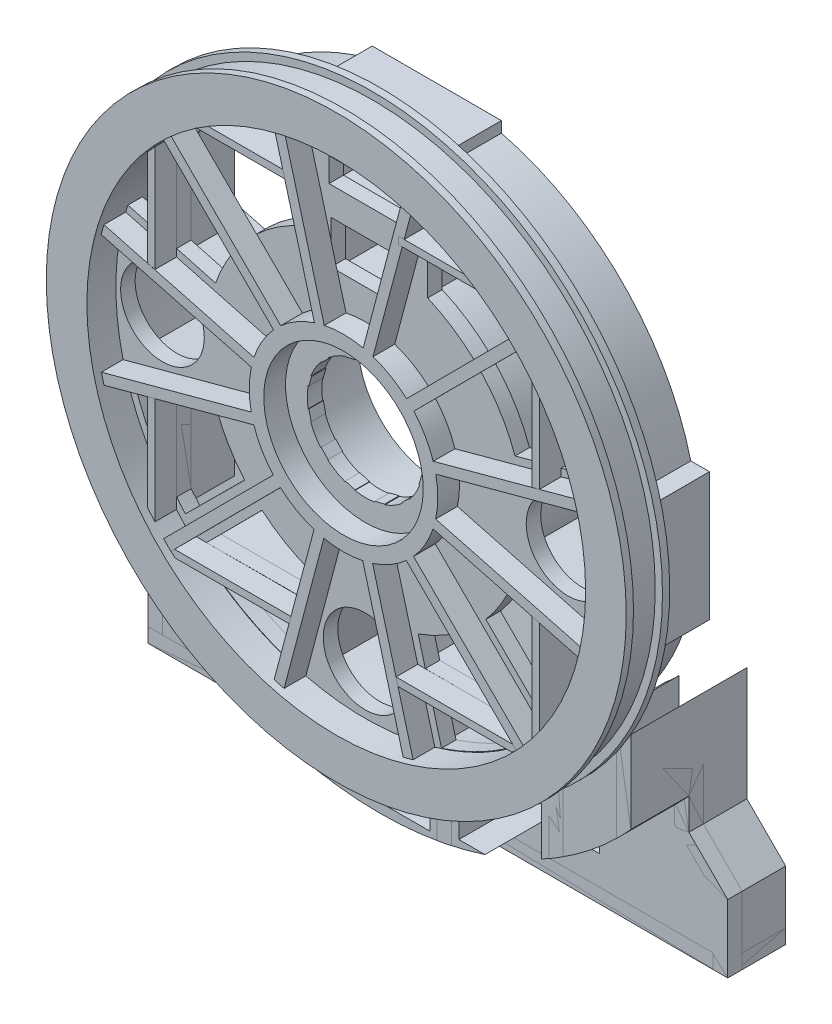
from build123d import *
from build123d.topology import SkipClean

# Parameters (mm, degrees)
SKETCH1_R                   = 200
BOSS_EXTRUDE1_DEPTH         = 5
SKETCH2_R                   = 195
BOSS_EXTRUDE2_DEPTH         = 10
SKETCH4_R                   = 180
SKETCH4_R_2                 = 172
BOSS_EXTRUDE3_DEPTH         = 40
CUT_EXTRUDE1_DEPTH          = 286.657137142
CUT_EXTRUDE1_DEPTH_BACK     = 286.657137142
SKETCH6_R                   = 40
SKETCH7_R                   = 172
CUT_EXTRUDE2_DEPTH          = 20
BOSS_EXTRUDE12_START        = -25
BOSS_EXTRUDE12_DEPTH        = 65
CIRPATTERN7_COUNT           = 12
SKETCH5_R                   = 104.5
SKETCH5_R_2                 = 96.5
BOSS_EXTRUDE14_DEPTH        = 40
SKETCH16_R                  = 63
SKETCH16_R_2                = 55
BOSS_EXTRUDE15_DEPTH        = 40
CUT_EXTRUDE9_START          = -40
SKETCH18_R                  = 55
CUT_EXTRUDE9_DEPTH          = 40
CUT_EXTRUDE13_DEPTH         = 40
BOSS_EXTRUDE18_START        = -40
SKETCH25_W                  = 60.032294261
SKETCH25_H                  = 45.012979572
BOSS_EXTRUDE18_DEPTH        = 40
SKETCH27_W                  = 60.032294261
SKETCH27_H                  = 45.012979572
SKETCH27_H_2                = 26.987020428
CUT_EXTRUDE15_DEPTH         = 40
CUT_EXTRUDE16_START         = -35
CUT_EXTRUDE16_DEPTH         = 35
BOSS_EXTRUDE19_START        = -44
SKETCH31_W                  = 5.866847787
SKETCH31_H                  = 9.437366397
SKETCH31_W_2                = 76.032294261
SKETCH31_W_3                = 7.195155409
BOSS_EXTRUDE19_DEPTH        = 44
BOSS_EXTRUDE20_DEPTH        = 80
BOSS_EXTRUDE21_DEPTH        = 80
BOSS_EXTRUDE21_2_DEPTH      = 80
BOSS_EXTRUDE26_DEPTH        = 50
CUT_EXTRUDE17_DEPTH         = 40
SKETCH41_W                  = 400
SKETCH41_H                  = 137.842811608
CUT_EXTRUDE18_DEPTH         = 452.7492864
BOSS_EXTRUDE29_DEPTH        = 40
BOSS_EXTRUDE29_DEPTH_BACK   = 10
SKETCH42_W                  = 400
SKETCH42_H                  = 10
BOSS_EXTRUDE31_DEPTH        = 40
CUT_EXTRUDE19_DEPTH         = 332.517722
CUT_EXTRUDE20_DEPTH         = 10
BOSS_EXTRUDE35_DEPTH        = 30
BOSS_EXTRUDE35_DEPTH_BACK   = 25
BOSS_EXTRUDE35_2_DEPTH      = 30
BOSS_EXTRUDE35_2_DEPTH_BACK = 25
BOSS_EXTRUDE35_3_DEPTH      = 30
BOSS_EXTRUDE35_3_DEPTH_BACK = 25
BOSS_EXTRUDE35_4_DEPTH      = 30
BOSS_EXTRUDE35_4_DEPTH_BACK = 25
BOSS_EXTRUDE35_5_DEPTH      = 30
BOSS_EXTRUDE35_5_DEPTH_BACK = 25
BOSS_EXTRUDE35_6_DEPTH      = 30
BOSS_EXTRUDE35_6_DEPTH_BACK = 25
BOSS_EXTRUDE35_7_DEPTH      = 30
BOSS_EXTRUDE35_7_DEPTH_BACK = 25
BOSS_EXTRUDE35_8_DEPTH      = 30
BOSS_EXTRUDE35_8_DEPTH_BACK = 25
CUT_EXTRUDE22_START         = -10.1
SKETCH51_W                  = 47.279154804
SKETCH51_H                  = 29.689444604
SKETCH51_W_2                = 50.032294261
SKETCH51_H_2                = 16.730666638
SKETCH51_H_3                = 10.868299713
SKETCH51_R                  = 28.871670661
SKETCH51_R_2                = 28.980669561
CUT_EXTRUDE22_DEPTH         = 10.1
BOSS_EXTRUDE36_START        = 15
SKETCH54_R                  = 65
SKETCH54_R_2                = 55
BOSS_EXTRUDE36_DEPTH        = 15
SKETCH55_R                  = 55
CUT_EXTRUDE23_DEPTH         = 15


with BuildPart() as part:
    # Sketch1 → Boss-Extrude1 (new body)
    with BuildSketch(Plane.XY):
        Circle(SKETCH1_R)
    boss_extrude1 = extrude(amount=BOSS_EXTRUDE1_DEPTH)

    # Sketch2 → Boss-Extrude2 (add)
    with BuildSketch(Plane.XY.offset(5)):
        Circle(SKETCH2_R)
    boss_extrude2 = extrude(amount=BOSS_EXTRUDE2_DEPTH)

    # Mirror2: Boss-Extrude2 across plane
    add(boss_extrude2.mirror(Plane.XY.offset(15)))

    # Mirror3: Boss-Extrude1 across plane
    add(boss_extrude1.mirror(Plane.XY.offset(15)))

    # Sketch4 → Boss-Extrude3 (add)
    with BuildSketch(Plane.XY):
        Circle(SKETCH4_R)
        Circle(SKETCH4_R_2, mode=Mode.SUBTRACT)
    extrude(amount=-BOSS_EXTRUDE3_DEPTH)

    # Sketch6 → Cut-Extrude1 (cut, two sides: drawn at the far end of the back side and taken through both)
    with BuildSketch(Plane(origin=(0, 0, 0), x_dir=(-1, 0, 0), z_dir=(0, 0, -1)).offset(-CUT_EXTRUDE1_DEPTH_BACK)):
        Circle(SKETCH6_R)
    extrude(amount=CUT_EXTRUDE1_DEPTH + CUT_EXTRUDE1_DEPTH_BACK, mode=Mode.SUBTRACT)

    # Sketch7 → Cut-Extrude2 (cut)
    with BuildSketch(Plane.XY.offset(30)):
        Circle(SKETCH7_R)
    extrude(amount=-CUT_EXTRUDE2_DEPTH, mode=Mode.SUBTRACT)

    # Sketch11 → Boss-Extrude12 (add)
    with BuildSketch(Plane(origin=(0, 0, 0), x_dir=(-1, 0, 0), z_dir=(0, 0, -1)).offset(BOSS_EXTRUDE12_START)):
        Polygon((7.035778174, -38.94988518), (13.739038842, -37.032866306), (48.739799741, -168.484156352), (41.858359492, -170.324504337), align=None)
    boss_extrude12 = extrude(amount=BOSS_EXTRUDE12_DEPTH)

    # CirPattern7: Boss-Extrude12 ×12 about axis
    cirpattern7_axis = Axis((0, 0, 0), (0, 0, 1))
    for i in range(1, CIRPATTERN7_COUNT):
        add(boss_extrude12.rotate(cirpattern7_axis, i * 360 / CIRPATTERN7_COUNT))

    # Sketch5 → Boss-Extrude14 (add)
    with BuildSketch(Plane(origin=(0, 0, 0), x_dir=(-1, 0, 0), z_dir=(0, 0, -1))):
        Circle(SKETCH5_R)
        Circle(SKETCH5_R_2, mode=Mode.SUBTRACT)
    extrude(amount=BOSS_EXTRUDE14_DEPTH)

    # Sketch16 → Boss-Extrude15 (add)
    with BuildSketch(Plane(origin=(0, 0, 0), x_dir=(-1, 0, 0), z_dir=(0, 0, -1))):
        Circle(SKETCH16_R)
        Circle(SKETCH16_R_2, mode=Mode.SUBTRACT)
    extrude(amount=BOSS_EXTRUDE15_DEPTH)

    # Sketch18 → Cut-Extrude9 (cut)
    with BuildSketch(Plane(origin=(0, 0, -40), x_dir=(-1, 0, 0), z_dir=(0, 0, -1)).offset(CUT_EXTRUDE9_START)):
        Circle(SKETCH18_R)
    extrude(amount=CUT_EXTRUDE9_DEPTH, mode=Mode.SUBTRACT)

    # Sketch20 → Cut-Extrude13 (cut)
    with SkipClean():  # the faces are left unmerged after this step: merging them gives an invalid solid
        with BuildSketch(Plane(origin=(0, 0, 0), x_dir=(-1, 0, 0), z_dir=(0, 0, -1))):
            with BuildLine():
                Line((-76.383232436, 71.315158295), (-124.056442132, 119.138571275))
                ThreePointArc((-124.056442132, 119.138571275), (0.082293709, 171.999980313), (124.170389449, 119.019806688))
                Line((124.170389449, 119.019806688), (76.298786502, 71.405498236))
                ThreePointArc((76.298786502, 71.405498236), (-0.061831263, 104.499981708), (-76.383232436, 71.315158295))
            make_face()
            with BuildLine():
                Line((-70.731344821, 65.645463361), (-47.053181493, 41.892697591))
                ThreePointArc((-47.053181493, 41.892697591), (-0.150655715, 62.999819864), (46.85228282, 42.117260055))
                Line((46.85228282, 42.117260055), (70.623866336, 65.761078943))
                ThreePointArc((70.623866336, 65.761078943), (-0.078928112, 96.499967722), (-70.731344821, 65.645463361))
            make_face()
        extrude(amount=CUT_EXTRUDE13_DEPTH, mode=Mode.SUBTRACT)

    # Sketch25 → Boss-Extrude18 (add)
    with SkipClean():  # the faces are left unmerged after this step: merging them gives an invalid solid
        with BuildSketch(Plane(origin=(0, 0, -40), x_dir=(-1, 0, 0), z_dir=(0, 0, -1)).offset(BOSS_EXTRUDE18_START)):
            with BuildLine():
                Line((38, 39.761790704), (38, 175.943172644))
                ThreePointArc((38, 175.943172644), (34.008709182, 176.758048472), (30, 177.482393493))
                Line((30, 177.482393493), (30, 130))
                Line((30, 130), (-30.032294261, 130))
                Line((-30.032294261, 130), (-30.032294261, 177.476931744))
                ThreePointArc((-30.032294261, 177.476931744), (-34.041012328, 176.751830202), (-38.032294261, 175.936194665))
                Line((-38.032294261, 175.936194665), (-38.032294261, 39.730902246))
                ThreePointArc((-38.032294261, 39.730902246), (-34.179881599, 43.089856044), (-30.032294261, 46.07668935))
                Line((-30.032294261, 46.07668935), (-30.032294261, 66.987020428))
                Line((-30.032294261, 66.987020428), (30, 66.987020428))
                Line((30, 66.987020428), (30, 46.097722286))
                ThreePointArc((30, 46.097722286), (34.147269397, 43.115704711), (38, 39.761790704))
            make_face()
            with Locations((-0.01614713, 99.493510214)):
                Rectangle(SKETCH25_W, SKETCH25_H, mode=Mode.SUBTRACT)
        extrude(amount=BOSS_EXTRUDE18_DEPTH)

    # Sketch27 → Cut-Extrude15 (cut)
    with SkipClean():  # the faces are left unmerged after this step: merging them gives an invalid solid
        with BuildSketch(Plane(origin=(0, 0, 0), x_dir=(-1, 0, 0), z_dir=(0, 0, -1))):
            with Locations((-0.01614713, 99.493510214)):
                Rectangle(SKETCH27_W, SKETCH27_H)
            with Locations((-0.01614713, 53.493510214)):
                Rectangle(SKETCH27_W, SKETCH27_H_2)
        extrude(amount=CUT_EXTRUDE15_DEPTH, mode=Mode.SUBTRACT)

    # Sketch30 → Cut-Extrude16 (cut)
    with SkipClean():  # the faces are left unmerged after this step: merging them gives an invalid solid
        with BuildSketch(Plane(origin=(0, 0, -50), x_dir=(-1, 0, 0), z_dir=(0, 0, -1)).offset(CUT_EXTRUDE16_START)):
            with BuildLine():
                Line((-38.032294261, 130), (38, 130))
                Line((38, 130), (38, 167.749813711))
                ThreePointArc((38, 167.749813711), (-0.016556603, 171.999999203), (-38.032294261, 167.742494894))
                Line((-38.032294261, 167.742494894), (-38.032294261, 130))
            make_face()
        extrude(amount=CUT_EXTRUDE16_DEPTH, mode=Mode.SUBTRACT)

    # Sketch31 → Boss-Extrude19 (add)
    with SkipClean():  # the faces are left unmerged after this step: merging them gives an invalid solid
        with BuildSketch(Plane(origin=(0, 0, -40), x_dir=(-1, 0, 0), z_dir=(0, 0, -1)).offset(BOSS_EXTRUDE19_START)):
            with BuildLine():
                ThreePointArc((-43.899142048, 166.303533719), (-40.972035783, 167.048772171), (-38.032294261, 167.742494894))
                Line((-38.032294261, 167.742494894), (-38.032294261, 172.64311533))
                Line((-38.032294261, 172.64311533), (-43.899142048, 172.64311533))
                Line((-43.899142048, 172.64311533), (-43.899142048, 166.303533719))
            make_face()
            with Locations((-40.965718155, 177.361798529)):
                Rectangle(SKETCH31_W, SKETCH31_H)
            with Locations((-0.016147131, 177.361798529)):
                Rectangle(SKETCH31_W_2, SKETCH31_H)
            with BuildLine():
                Line((-38.032294261, 172.64311533), (-38.032294261, 167.742494894))
                ThreePointArc((-38.032294261, 167.742494894), (-0.016556603, 171.999999203), (38, 167.749813711))
                Line((38, 167.749813711), (38, 172.64311533))
                Line((38, 172.64311533), (-38.032294261, 172.64311533))
            make_face()
            with BuildLine():
                Line((38, 172.64311533), (38, 167.749813711))
                ThreePointArc((38, 167.749813711), (41.607245787, 166.891692717), (45.195155409, 165.956012026))
                Line((45.195155409, 165.956012026), (45.195155409, 172.64311533))
                Line((45.195155409, 172.64311533), (38, 172.64311533))
            make_face()
            with Locations((41.597577704, 177.361798529)):
                Rectangle(SKETCH31_W_3, SKETCH31_H)
        extrude(amount=BOSS_EXTRUDE19_DEPTH)

    # Sketch32 → Boss-Extrude20 (add)
    with SkipClean():  # the faces are left unmerged after this step: merging them gives an invalid solid
        with BuildSketch(Plane.XY):
            with BuildLine():
                Line((125.869176934, -389.842811608), (126.470649272, -154.528527603))
                ThreePointArc((126.470649272, -154.528527603), (121.628078628, -158.368246375), (116.66900432, -162.056269245))
                Line((116.66900432, -162.056269245), (116.086773179, -389.842811608))
                Line((116.086773179, -389.842811608), (125.869176934, -389.842811608))
            make_face()
            with BuildLine():
                Line((126.470649272, -154.528527603), (126.538416981, -128.015737423))
                ThreePointArc((126.538416981, -128.015737423), (121.718930634, -132.606568183), (116.733008017, -137.016075113))
                Line((116.733008017, -137.016075113), (116.66900432, -162.056269245))
                ThreePointArc((116.66900432, -162.056269245), (121.628078628, -158.368246375), (126.470649272, -154.528527603))
            make_face()
            with BuildLine():
                Line((49.586808273, -193.429675634), (49.586808273, -173.035107551))
                ThreePointArc((49.586808273, -173.035107551), (44.605146714, -174.385724435), (39.586808273, -175.592951484))
                Line((39.586808273, -175.592951484), (39.586808273, -195.721167944))
                ThreePointArc((39.586808273, -195.721167944), (44.601526949, -194.639653628), (49.586808273, -193.429675634))
            make_face()
            with BuildLine():
                Line((49.586808273, -389.842811608), (49.586808273, -193.429675634))
                ThreePointArc((49.586808273, -193.429675634), (44.601526949, -194.639653628), (39.586808273, -195.721167944))
                Line((39.586808273, -195.721167944), (39.586808273, -389.842811608))
                Line((39.586808273, -389.842811608), (49.586808273, -389.842811608))
            make_face()
            with BuildLine():
                ThreePointArc((-39.427863087, -175.628709534), (-44.446127643, -174.426321802), (-49.427863087, -173.080577624))
                Line((-49.427863087, -173.080577624), (-49.427863087, -193.470352564))
                ThreePointArc((-49.427863087, -193.470352564), (-44.442523811, -194.676020731), (-39.427863087, -195.753249227))
                Line((-39.427863087, -195.753249227), (-39.427863087, -175.628709534))
            make_face()
            with BuildLine():
                ThreePointArc((-39.427863087, -195.753249227), (-44.442523811, -194.676020731), (-49.427863087, -193.470352564))
                Line((-49.427863087, -193.470352564), (-49.427863087, -389.842811608))
                Line((-49.427863087, -389.842811608), (-39.427863087, -389.842811608))
                Line((-39.427863087, -389.842811608), (-39.427863087, -195.753249227))
            make_face()
            with BuildLine():
                ThreePointArc((-116.53812441, -137.181870373), (-121.624499416, -132.693184233), (-126.53812441, -128.016026617))
                Line((-126.53812441, -128.016026617), (-126.53812441, -154.473279376))
                ThreePointArc((-126.53812441, -154.473279376), (-121.598726479, -158.390784736), (-116.53812441, -162.150413288))
                Line((-116.53812441, -162.150413288), (-116.53812441, -137.181870373))
            make_face()
            with BuildLine():
                ThreePointArc((-116.53812441, -162.150413288), (-121.598726479, -158.390784736), (-126.53812441, -154.473279376))
                Line((-126.53812441, -154.473279376), (-126.53812441, -389.842811608))
                Line((-126.53812441, -389.842811608), (-116.53812441, -389.842811608))
                Line((-116.53812441, -389.842811608), (-116.53812441, -162.150413288))
            make_face()
        extrude(amount=-BOSS_EXTRUDE20_DEPTH)


with BuildPart() as body_2:
    # Sketch33 → Boss-Extrude21 (new body)
    with BuildSketch(Plane(origin=(0, 0, 0), x_dir=(-1, 0, 0), z_dir=(0, 0, -1))):
        with BuildLine():
            ThreePointArc((-163.205080757, -115.603207633), (-168.385908599, -107.91749527), (-173.205080757, -100))
            Line((-173.205080757, -100), (-173.205080757, -178.365564659))
            Line((-173.205080757, -178.365564659), (-200, -205.160483902))
            Line((-200, -205.160483902), (-200, -389.842811608))
            Line((-200, -389.842811608), (-190, -389.842811608))
            Line((-190, -389.842811608), (-190, -205.160483902))
            Line((-190, -205.160483902), (-163.205080757, -178.365564659))
            Line((-163.205080757, -178.365564659), (-163.205080757, -115.603207633))
        make_face()
    extrude(amount=BOSS_EXTRUDE21_DEPTH)


with BuildPart() as body_3:
    # Sketch33 → Boss-Extrude21 2 (new body)
    with BuildSketch(Plane(origin=(0, 0, 0), x_dir=(-1, 0, 0), z_dir=(0, 0, -1))):
        with BuildLine():
            ThreePointArc((173.205080757, -100), (168.385908599, -107.91749527), (163.205080757, -115.603207633))
            Line((163.205080757, -115.603207633), (163.205080757, -178.648465684))
            Line((163.205080757, -178.648465684), (190, -205.443384928))
            Line((190, -205.443384928), (190, -389.842811608))
            Line((190, -389.842811608), (200, -389.842811608))
            Line((200, -389.842811608), (200, -205.443384928))
            Line((200, -205.443384928), (173.205080757, -178.648465684))
            Line((173.205080757, -178.648465684), (173.205080757, -100))
        make_face()
    extrude(amount=BOSS_EXTRUDE21_2_DEPTH)


with BuildPart() as body_4:
    # Sketch34 → Boss-Extrude26 (new body)
    with BuildSketch(Plane(origin=(0, 0, 0), x_dir=(-1, 0, 0), z_dir=(0, 0, -1))):
        with BuildLine():
            Line((-200, -205.160483902), (-200, -389.842811608))
            Line((-200, -389.842811608), (200, -389.842811608))
            Line((200, -389.842811608), (200, -205.443384928))
            Line((200, -205.443384928), (173.205080757, -178.648465684))
            Line((173.205080757, -178.648465684), (173.205080757, -100))
            ThreePointArc((173.205080757, -100), (0, -200), (-173.205080757, -100))
            Line((-173.205080757, -100), (-173.205080757, -178.365564659))
            Line((-173.205080757, -178.365564659), (-200, -205.160483902))
        make_face()
    extrude(amount=BOSS_EXTRUDE26_DEPTH)


with BuildPart() as cut_extrude17_tool:
    # Sketch39 → Cut-Extrude17 (new body)
    with SkipClean():  # the faces are left unmerged after this step: merging them gives an invalid solid
        with BuildSketch(Plane.XY.offset(10)):
            with BuildLine():
                Line((-233.56, 0), (-438.152276911, 0))
                ThreePointArc((-438.152276911, 0), (0, -438.152276911), (438.152276911, 0))
                Line((438.152276911, 0), (233.56, 0))
                ThreePointArc((233.56, 0), (0, -233.56), (-233.56, 0))
            make_face()
        extrude(amount=-CUT_EXTRUDE17_DEPTH)


with BuildPart() as part_1:
    with SkipClean():  # the faces are left unmerged after this step: merging them gives an invalid solid
        add(part.part)

        # Cut-Extrude17: cut by cut_extrude17_tool
        add(cut_extrude17_tool.part, mode=Mode.SUBTRACT)


with BuildPart() as body_2_1:
    with SkipClean():  # the faces are left unmerged after this step: merging them gives an invalid solid
        add(body_2.part)

        # Cut-Extrude17: cut by cut_extrude17_tool
        add(cut_extrude17_tool.part, mode=Mode.SUBTRACT)


with BuildPart() as body_3_1:
    with SkipClean():  # the faces are left unmerged after this step: merging them gives an invalid solid
        add(body_3.part)

        # Cut-Extrude17: cut by cut_extrude17_tool
        add(cut_extrude17_tool.part, mode=Mode.SUBTRACT)


with BuildPart() as body_4_1:
    with SkipClean():  # the faces are left unmerged after this step: merging them gives an invalid solid
        add(body_4.part)

        # Cut-Extrude17: cut by cut_extrude17_tool
        add(cut_extrude17_tool.part, mode=Mode.SUBTRACT)


with BuildPart() as cut_extrude18_tool:
    # Sketch41 → Cut-Extrude18 (new, through all)
    with SkipClean():  # the faces are left unmerged after this step: merging them gives an invalid solid
        with BuildSketch(Plane.XY.offset(30)):
            with Locations((0, -320.921405804)):
                Rectangle(SKETCH41_W, SKETCH41_H)
        extrude(amount=-CUT_EXTRUDE18_DEPTH)


with BuildPart() as part_2:
    with SkipClean():  # the faces are left unmerged after this step: merging them gives an invalid solid
        add(part_1.part)

        # Cut-Extrude18: cut by cut_extrude18_tool
        add(cut_extrude18_tool.part, mode=Mode.SUBTRACT)

    # Sketch43 → Boss-Extrude31 (add)
    with SkipClean():  # the faces are left unmerged after this step: merging them gives an invalid solid
        with BuildSketch(Plane(origin=(0, 0, 0), x_dir=(-1, 0, 0), z_dir=(0, 0, -1))):
            with BuildLine():
                Line((-187.42, 44.121264877), (-187.42, -44.324795087))
                Line((-187.42, -44.324795087), (-168.54945165, -44.324795087))
                ThreePointArc((-168.54945165, -44.324795087), (-175.880421046, -0.245537623), (-170.55962348, 44.121264877))
                Line((-170.55962348, 44.121264877), (-187.42, 44.121264877))
            make_face()
            with BuildLine():
                Line((187.42, -44.089067058), (187.42, 44.356992906))
                Line((187.42, 44.356992906), (170.559634974, 44.376680386))
                ThreePointArc((170.559634974, 44.376680386), (175.883301427, 0), (168.54945165, -44.089067058))
                Line((168.54945165, -44.089067058), (187.42, -44.089067058))
            make_face()
        extrude(amount=BOSS_EXTRUDE31_DEPTH)


with BuildPart() as body_2_2:
    with SkipClean():  # the faces are left unmerged after this step: merging them gives an invalid solid
        add(body_2_1.part)

        # Cut-Extrude18: cut by cut_extrude18_tool
        add(cut_extrude18_tool.part, mode=Mode.SUBTRACT)


with BuildPart() as body_3_2:
    with SkipClean():  # the faces are left unmerged after this step: merging them gives an invalid solid
        add(body_3_1.part)

        # Cut-Extrude18: cut by cut_extrude18_tool
        add(cut_extrude18_tool.part, mode=Mode.SUBTRACT)


with BuildPart() as body_4_2:
    with SkipClean():  # the faces are left unmerged after this step: merging them gives an invalid solid
        add(body_4_1.part)

        # Cut-Extrude18: cut by cut_extrude18_tool
        add(cut_extrude18_tool.part, mode=Mode.SUBTRACT)

    # Sketch45 → Cut-Extrude19 (cut, through all)
    with BuildSketch(Plane(origin=(0, 0, -50), x_dir=(-1, 0, 0), z_dir=(0, 0, -1))):
        with BuildLine():
            Line((34.427863087, -227), (34.427863087, -202.08840205))
            ThreePointArc((34.427863087, -202.08840205), (-0.080623006, -204.999984146), (-34.586808273, -202.061259754))
            Line((-34.586808273, -202.061259754), (-34.586808273, -227))
            Line((-34.586808273, -227), (34.427863087, -227))
        make_face()
        with BuildLine():
            Line((54.427863087, -197.642626272), (54.427863087, -222))
            Line((54.427863087, -222), (111.53812441, -222))
            Line((111.53812441, -222), (111.53812441, -172.000717449))
            ThreePointArc((111.53812441, -172.000717449), (83.967577811, -187.0145606), (54.427863087, -197.642626272))
        make_face()
        with BuildLine():
            ThreePointArc((-54.586808273, -197.598786339), (-84.030627785, -186.98623905), (-111.515769511, -172.015211974))
            Line((-111.515769511, -172.015211974), (-111.515769511, -222))
            Line((-111.515769511, -222), (-54.586808273, -222))
            Line((-54.586808273, -222), (-54.586808273, -197.598786339))
        make_face()
    extrude(amount=-CUT_EXTRUDE19_DEPTH, mode=Mode.SUBTRACT)


with BuildPart() as body_5:
    # Sketch42 → Boss-Extrude29 (new, two sides: drawn at the far end of the back side and taken through both)
    with BuildSketch(Plane(origin=(0, 0, -40), x_dir=(-1, 0, 0), z_dir=(0, 0, -1)).offset(-BOSS_EXTRUDE29_DEPTH_BACK)):
        with Locations((0, -247)):
            Rectangle(SKETCH42_W, SKETCH42_H)
    extrude(amount=BOSS_EXTRUDE29_DEPTH + BOSS_EXTRUDE29_DEPTH_BACK)


with BuildPart() as cut_extrude20_tool:
    # Sketch48 → Cut-Extrude20 (new body)
    with SkipClean():  # the faces are left unmerged after this step: merging them gives an invalid solid
        with BuildSketch(Plane.XY.offset(-30)):
            with BuildLine():
                Line((-200, -252), (200, -252))
                Line((200, -252), (200, -155.878801719))
                Line((200, -155.878801719), (173.931230016, -155.878801719))
                ThreePointArc((173.931230016, -155.878801719), (0, -233.56), (-173.931230016, -155.878801719))
                Line((-173.931230016, -155.878801719), (-200, -155.878801719))
                Line((-200, -155.878801719), (-200, -252))
            make_face()
        extrude(amount=-CUT_EXTRUDE20_DEPTH)


with BuildPart() as part_3:
    with SkipClean():  # the faces are left unmerged after this step: merging them gives an invalid solid
        add(part_2.part)

        # Cut-Extrude20: cut by cut_extrude20_tool
        add(cut_extrude20_tool.part, mode=Mode.SUBTRACT)


with BuildPart() as body_2_3:
    with SkipClean():  # the faces are left unmerged after this step: merging them gives an invalid solid
        add(body_2_2.part)

        # Cut-Extrude20: cut by cut_extrude20_tool
        add(cut_extrude20_tool.part, mode=Mode.SUBTRACT)


with BuildPart() as body_3_3:
    with SkipClean():  # the faces are left unmerged after this step: merging them gives an invalid solid
        add(body_3_2.part)

        # Cut-Extrude20: cut by cut_extrude20_tool
        add(cut_extrude20_tool.part, mode=Mode.SUBTRACT)


with BuildPart() as body_4_3:
    with SkipClean():  # the faces are left unmerged after this step: merging them gives an invalid solid
        add(body_4_2.part)

        # Cut-Extrude20: cut by cut_extrude20_tool
        add(cut_extrude20_tool.part, mode=Mode.SUBTRACT)


with BuildPart() as body_5_1:
    with SkipClean():  # the faces are left unmerged after this step: merging them gives an invalid solid
        add(body_5.part)

        # Cut-Extrude20: cut by cut_extrude20_tool
        add(cut_extrude20_tool.part, mode=Mode.SUBTRACT)


with BuildPart() as body_6:
    # Sketch50 → Boss-Extrude35 (new, two sides: drawn at the far end of the back side and taken through both)
    with BuildSketch(Plane(origin=(0, 0, 0), x_dir=(-1, 0, 0), z_dir=(0, 0, -1)).offset(-BOSS_EXTRUDE35_DEPTH_BACK)):
        Polygon((-135.078802669, -39.845152936), (-130.078802669, -38.513832381), (-130.078802669, -112.076168804), (-135.078802669, -106.197517484), align=None)
    extrude(amount=BOSS_EXTRUDE35_DEPTH + BOSS_EXTRUDE35_DEPTH_BACK)


with BuildPart() as body_7:
    # Sketch50 → Boss-Extrude35 2 (new, two sides: drawn at the far end of the back side and taken through both)
    with BuildSketch(Plane(origin=(0, 0, 0), x_dir=(-1, 0, 0), z_dir=(0, 0, -1)).offset(-BOSS_EXTRUDE35_2_DEPTH_BACK)):
        Polygon((-116.197029051, -126.556442132), (-37.569617269, -126.556442132), (-36.215420659, -121.556442132), (-116.607707583, -121.556442132), (-119.138571275, -124.056442132), align=None)
    extrude(amount=BOSS_EXTRUDE35_2_DEPTH + BOSS_EXTRUDE35_2_DEPTH_BACK)


with BuildPart() as body_8:
    # Sketch50 → Boss-Extrude35 3 (new, two sides: drawn at the far end of the back side and taken through both)
    with BuildSketch(Plane(origin=(0, 0, 0), x_dir=(-1, 0, 0), z_dir=(0, 0, -1)).offset(-BOSS_EXTRUDE35_3_DEPTH_BACK)):
        Polygon((116.533243385, -121.670389449), (36.274973709, -121.670389449), (37.606294264, -126.670389449), (116.06302922, -126.670389449), (119.019806688, -124.170389449), align=None)
    extrude(amount=BOSS_EXTRUDE35_3_DEPTH + BOSS_EXTRUDE35_3_DEPTH_BACK)


with BuildPart() as body_9:
    # Sketch50 → Boss-Extrude35 4 (new, two sides: drawn at the far end of the back side and taken through both)
    with BuildSketch(Plane(origin=(0, 0, 0), x_dir=(-1, 0, 0), z_dir=(0, 0, -1)).offset(-BOSS_EXTRUDE35_4_DEPTH_BACK)):
        Polygon((-130.073869782, 38.637040002), (-135.073869782, 39.876471599), (-135.073869782, 106.484089263), (-130.073869782, 111.958915671), align=None)
    extrude(amount=BOSS_EXTRUDE35_4_DEPTH + BOSS_EXTRUDE35_4_DEPTH_BACK)


with BuildPart() as body_10:
    # Sketch50 → Boss-Extrude35 5 (new, two sides: drawn at the far end of the back side and taken through both)
    with BuildSketch(Plane(origin=(0, 0, 0), x_dir=(-1, 0, 0), z_dir=(0, 0, -1)).offset(-BOSS_EXTRUDE35_5_DEPTH_BACK)):
        Polygon((130.073869782, -38.522274989), (135.073869782, -39.876471599), (135.073869782, -106.197517484), (130.073869782, -112.076168804), align=None)
    extrude(amount=BOSS_EXTRUDE35_5_DEPTH + BOSS_EXTRUDE35_5_DEPTH_BACK)


with BuildPart() as body_11:
    # Sketch50 → Boss-Extrude35 6 (new, two sides: drawn at the far end of the back side and taken through both)
    with BuildSketch(Plane(origin=(0, 0, 0), x_dir=(-1, 0, 0), z_dir=(0, 0, -1)).offset(-BOSS_EXTRUDE35_6_DEPTH_BACK)):
        Polygon((-99.880891595, 137.527881132), (-103.288943059, 137.527881132), (-95.488015844, 142.527881132), (-38.032294261, 142.527881132), (-38.032294261, 137.527881132), align=None)
    extrude(amount=BOSS_EXTRUDE35_6_DEPTH + BOSS_EXTRUDE35_6_DEPTH_BACK)


with BuildPart() as body_12:
    # Sketch50 → Boss-Extrude35 7 (new, two sides: drawn at the far end of the back side and taken through both)
    with BuildSketch(Plane(origin=(0, 0, 0), x_dir=(-1, 0, 0), z_dir=(0, 0, -1)).offset(-BOSS_EXTRUDE35_7_DEPTH_BACK)):
        Polygon((38, 137.527881132), (103.296088558, 137.527881132), (95.676853998, 142.527881132), (38, 142.527881132), align=None)
    extrude(amount=BOSS_EXTRUDE35_7_DEPTH + BOSS_EXTRUDE35_7_DEPTH_BACK)


with BuildPart() as body_13:
    # Sketch50 → Boss-Extrude35 8 (new, two sides: drawn at the far end of the back side and taken through both)
    with BuildSketch(Plane(origin=(0, 0, 0), x_dir=(-1, 0, 0), z_dir=(0, 0, -1)).offset(-BOSS_EXTRUDE35_8_DEPTH_BACK)):
        Polygon((135.078802669, 39.845152936), (135.078802669, 106.47871651), (130.078802669, 111.962203582), (130.078802669, 38.630262338), align=None)
    extrude(amount=BOSS_EXTRUDE35_8_DEPTH + BOSS_EXTRUDE35_8_DEPTH_BACK)


with BuildPart() as cut_extrude22_tool:
    # Sketch51 → Cut-Extrude22 (new body)
    with SkipClean():  # the faces are left unmerged after this step: merging them gives an invalid solid
        with BuildSketch(Plane(origin=(0, 0, 0), x_dir=(-1, 0, 0), z_dir=(0, 0, -1)).offset(CUT_EXTRUDE22_START)):
            with BuildLine():
                ThreePointArc((-43.032294261, 100.689977906), (-79.88925777, 74.88629042), (-103.258836778, 36.439849441))
                Line((-103.258836778, 36.439849441), (-130.073869782, 43.702414799))
                Line((-130.073869782, 43.702414799), (-130.073869782, 104.736757636))
                ThreePointArc((-130.073869782, 104.736757636), (-113.608397153, 122.401519992), (-94.767386676, 137.506881364))
                Line((-94.767386676, 137.506881364), (-43.032294261, 137.527881132))
                Line((-43.032294261, 137.527881132), (-43.032294261, 100.689977906))
            make_face()
            with BuildLine():
                Line((43.032294261, 100.689977906), (43.032294261, 137.527881132))
                Line((43.032294261, 137.527881132), (94.767386676, 137.506881364))
                ThreePointArc((94.767386676, 137.506881364), (113.608397153, 122.401519992), (130.073869782, 104.736757636))
                Line((130.073869782, 104.736757636), (130.073869782, 43.702414799))
                Line((130.073869782, 43.702414799), (103.258836778, 36.439849441))
                ThreePointArc((103.258836778, 36.439849441), (79.88925777, 74.88629042), (43.032294261, 100.689977906))
            make_face()
            with Locations((0, 100.689977906)):
                Rectangle(SKETCH51_W, SKETCH51_H)
            with Locations((-0.016147131, 143.365333319)):
                Rectangle(SKETCH51_W_2, SKETCH51_H_2)
            with Locations((-0.016147131, 162.164816495)):
                Rectangle(SKETCH51_W_2, SKETCH51_H_3)
            with Locations((139.872463166, 0)):
                Circle(SKETCH51_R)
            with Locations((-139.872463166, 0)):
                Circle(SKETCH51_R)
            with Locations((0, -137.864380452)):
                Circle(SKETCH51_R_2)
            with BuildLine():
                ThreePointArc((-52.586669067, -163.499116066), (-86.234331172, -148.375851313), (-116.06302922, -126.670389449))
                Line((-116.06302922, -126.670389449), (-42.771288324, -126.635790019))
                Line((-42.771288324, -126.635790019), (-52.586669067, -163.499116066))
            make_face()
            with BuildLine():
                Line((-41.402321129, -121.494401681), (-36.537641807, -103.224273944))
                ThreePointArc((-36.537641807, -103.224273944), (-54.794906142, -94.803840961), (-71.204851095, -83.187253715))
                Line((-71.204851095, -83.187253715), (-109.481152331, -121.670389449))
                Line((-109.481152331, -121.670389449), (-41.402321129, -121.494401681))
            make_face()
            with BuildLine():
                ThreePointArc((-103.224273944, -36.537641807), (-94.803840961, -54.794906142), (-83.187253715, -71.204851095))
                Line((-83.187253715, -71.204851095), (-124.030083865, -111.828164147))
                ThreePointArc((-124.030083865, -111.828164147), (-127.103994027, -108.321626199), (-130.078802669, -104.730631127))
                Line((-130.078802669, -104.730631127), (-130.073869782, -43.686725576))
                Line((-130.073869782, -43.686725576), (-103.224273944, -36.537641807))
            make_face()
            with BuildLine():
                Line((-158.904999928, -51.363420817), (-135.078802669, -45.019359583))
                Line((-135.078802669, -45.019359583), (-135.078802669, -98.197337385))
                ThreePointArc((-135.078802669, -98.197337385), (-148.845466785, -75.723358467), (-158.904999928, -51.363420817))
            make_face()
            with BuildLine():
                Line((52.586669067, -163.499116066), (42.771288324, -126.635790019))
                Line((42.771288324, -126.635790019), (116.06302922, -126.670389449))
                ThreePointArc((116.06302922, -126.670389449), (86.234331172, -148.375851313), (52.586669067, -163.499116066))
            make_face()
            with BuildLine():
                ThreePointArc((36.537641807, -103.224273944), (54.794906142, -94.803840961), (71.204851095, -83.187253715))
                Line((71.204851095, -83.187253715), (109.481152331, -121.670389449))
                Line((109.481152331, -121.670389449), (41.402321129, -121.494401681))
                Line((41.402321129, -121.494401681), (36.537641807, -103.224273944))
            make_face()
            with BuildLine():
                Line((130.073869782, -43.686725576), (103.224273944, -36.537641807))
                ThreePointArc((103.224273944, -36.537641807), (94.803840961, -54.794906142), (83.187253715, -71.204851095))
                Line((83.187253715, -71.204851095), (124.030083865, -111.828164147))
                ThreePointArc((124.030083865, -111.828164147), (127.103994027, -108.321626199), (130.078802669, -104.730631127))
                Line((130.078802669, -104.730631127), (130.073869782, -43.686725576))
            make_face()
            with BuildLine():
                ThreePointArc((158.904999928, -51.363420817), (148.845466785, -75.723358467), (135.078802669, -98.197337385))
                Line((135.078802669, -98.197337385), (135.078802669, -45.019359583))
                Line((135.078802669, -45.019359583), (158.904999928, -51.363420817))
            make_face()
            with BuildLine():
                Line((-43.032294261, 142.527881132), (-95.488015844, 142.527881132))
                ThreePointArc((-95.488015844, 142.527881132), (-70.224151847, 156.616269576), (-43.032294261, 166.482798555))
                Line((-43.032294261, 166.482798555), (-43.032294261, 142.527881132))
            make_face()
            with BuildLine():
                Line((43.032294261, 142.527881132), (43.032294261, 166.482798555))
                ThreePointArc((43.032294261, 166.482798555), (70.224151847, 156.616269576), (95.488015844, 142.527881132))
                Line((95.488015844, 142.527881132), (43.032294261, 142.527881132))
            make_face()
            with BuildLine():
                Line((-135.073869782, 45.05661141), (-163.692826687, 52.807750295))
                ThreePointArc((-163.692826687, 52.807750295), (-151.77514888, 80.921592806), (-135.073869782, 106.484974068))
                Line((-135.073869782, 106.484974068), (-135.073869782, 45.05661141))
            make_face()
            with BuildLine():
                Line((135.073869782, 45.05661141), (135.073869782, 106.484974068))
                ThreePointArc((135.073869782, 106.484974068), (151.77514888, 80.921592806), (163.692826687, 52.807750295))
                Line((163.692826687, 52.807750295), (135.073869782, 45.05661141))
            make_face()
        extrude(amount=CUT_EXTRUDE22_DEPTH)


with BuildPart() as part_4:
    with SkipClean():  # the faces are left unmerged after this step: merging them gives an invalid solid
        add(part_3.part)

        # Cut-Extrude22: cut by cut_extrude22_tool
        add(cut_extrude22_tool.part, mode=Mode.SUBTRACT)

    # Sketch54 → Boss-Extrude36 (add)
    with SkipClean():  # the faces are left unmerged after this step: merging them gives an invalid solid
        with BuildSketch(Plane.XY.offset(10).offset(BOSS_EXTRUDE36_START)):
            Circle(SKETCH54_R)
            Circle(SKETCH54_R_2, mode=Mode.SUBTRACT)
        extrude(amount=-BOSS_EXTRUDE36_DEPTH)

    # Sketch55 → Cut-Extrude23 (cut)
    with SkipClean():  # the faces are left unmerged after this step: merging them gives an invalid solid
        with BuildSketch(Plane.XY.offset(25)):
            Circle(SKETCH55_R)
        extrude(amount=-CUT_EXTRUDE23_DEPTH, mode=Mode.SUBTRACT)


with BuildPart() as body_10_1:
    with SkipClean():  # the faces are left unmerged after this step: merging them gives an invalid solid
        add(body_10.part)

        # Cut-Extrude22: cut by cut_extrude22_tool
        add(cut_extrude22_tool.part, mode=Mode.SUBTRACT)


with BuildPart() as body_8_1:
    with SkipClean():  # the faces are left unmerged after this step: merging them gives an invalid solid
        add(body_8.part)

        # Cut-Extrude22: cut by cut_extrude22_tool
        add(cut_extrude22_tool.part, mode=Mode.SUBTRACT)


with BuildPart() as body_7_1:
    with SkipClean():  # the faces are left unmerged after this step: merging them gives an invalid solid
        add(body_7.part)

        # Cut-Extrude22: cut by cut_extrude22_tool
        add(cut_extrude22_tool.part, mode=Mode.SUBTRACT)


solid = Compound([body_2_3.part, body_3_3.part, body_4_3.part, body_5_1.part, body_6.part, body_9.part, body_11.part, body_12.part, body_13.part, part_4.part, body_10_1.part, body_8_1.part, body_7_1.part])
